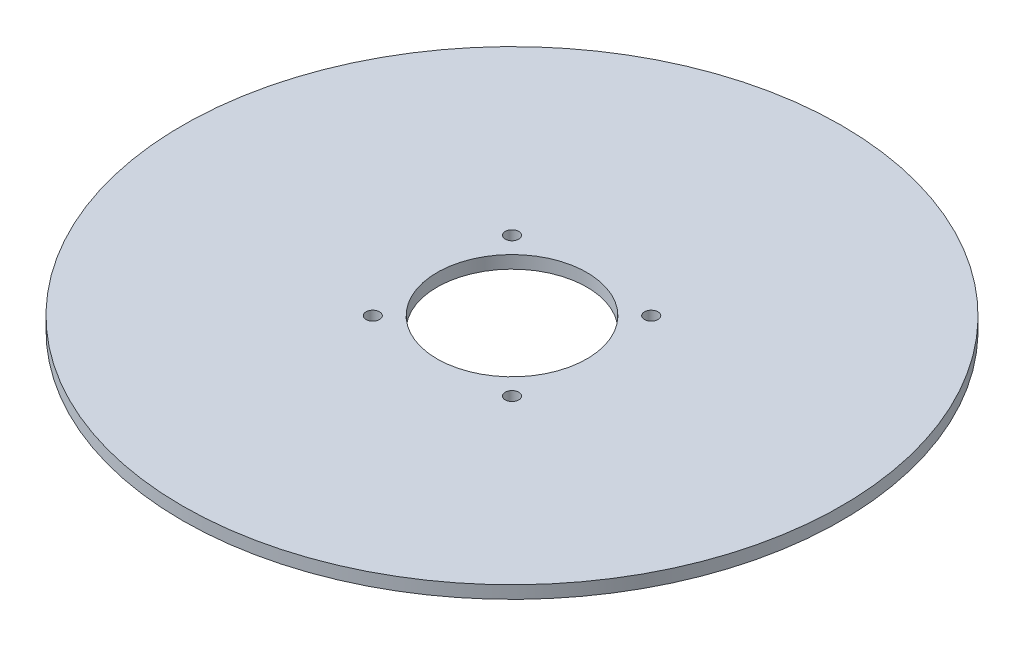
from build123d import *

# Parameters (mm, degrees)
SKETCH1_R               = 165
BOSS_EXTRUDE1_DEPTH     = 6.35
F_1_4_CLEARANCE_HOLE2_D = 6.7564
SKETCH6_R               = 37.5
CUT_EXTRUDE1_DEPTH      = 234.431622751


with BuildPart() as part:
    # Sketch1 → Boss-Extrude1 (new body)
    with BuildSketch(Plane(origin=(0, 0, 0), x_dir=(1, 0, 0), z_dir=(0, 1, 0))):
        Circle(SKETCH1_R)
    extrude(amount=BOSS_EXTRUDE1_DEPTH)

    # 1_4 Clearance Hole2 (through all)
    with Locations(Plane(origin=(0, 6.35, 0), x_dir=(1, 0, 0), z_dir=(0, 1, 0))):
        with Locations((-34.85, 34.85), (34.85, -34.85), (34.85, 34.85), (-34.85, -34.85)):
            Hole(F_1_4_CLEARANCE_HOLE2_D / 2)

    # Sketch6 → Cut-Extrude1 (cut, through all)
    with BuildSketch(Plane(origin=(0, 6.35, 0), x_dir=(1, 0, 0), z_dir=(0, 1, 0))):
        Circle(SKETCH6_R)
    extrude(amount=-CUT_EXTRUDE1_DEPTH, mode=Mode.SUBTRACT)


solid = part.part
